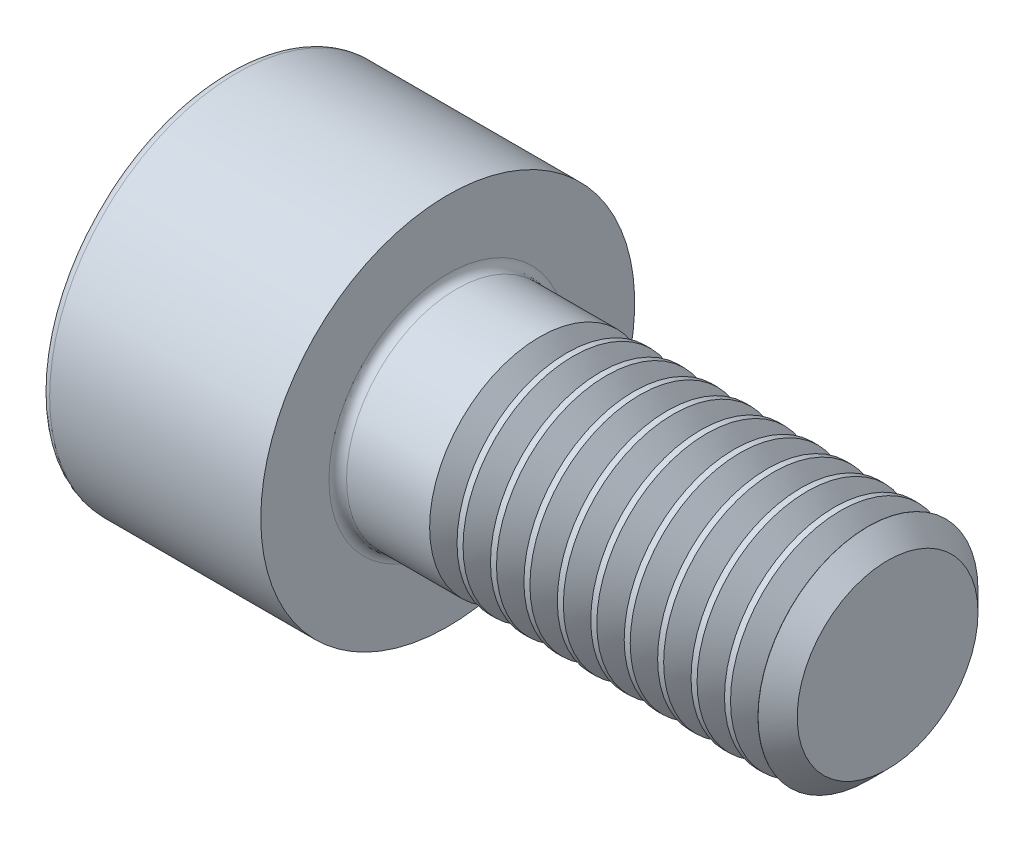
from build123d import *

# Parameters (mm, degrees)
SKETCH1_W            = 5
SKETCH1_H            = 4.25
SKETCH2_R            = 2.5
BOSS_EXTRUDE1_DEPTH  = 2.088407645
SKETCH3_R            = 2.5
BOSS_EXTRUDE2_DEPTH  = 0.311592355
BOSS_EXTRUDE2_TAPER  = 55
SKETCH4_R            = 2.055
BOSS_EXTRUDE3_DEPTH  = 0.311592355
BOSS_EXTRUDE3_TAPER  = -55
SKETCH5_R            = 2.5
BOSS_EXTRUDE4_DEPTH  = 0.136815291
SKETCH6_R            = 2.5
BOSS_EXTRUDE5_DEPTH  = 0.311592355
BOSS_EXTRUDE5_TAPER  = 55
SKETCH7_R            = 2.055
BOSS_EXTRUDE6_DEPTH  = 0.311592355
BOSS_EXTRUDE6_TAPER  = -55
SKETCH8_R            = 2.5
BOSS_EXTRUDE7_DEPTH  = 0.136815291
SKETCH9_R            = 2.5
BOSS_EXTRUDE8_DEPTH  = 0.311592355
BOSS_EXTRUDE8_TAPER  = 55
SKETCH10_R           = 2.055
BOSS_EXTRUDE9_DEPTH  = 0.311592355
BOSS_EXTRUDE9_TAPER  = -55
SKETCH11_R           = 2.5
BOSS_EXTRUDE10_DEPTH = 0.136815291
SKETCH12_R           = 2.5
BOSS_EXTRUDE11_DEPTH = 0.311592355
BOSS_EXTRUDE11_TAPER = 55
SKETCH13_R           = 2.055
BOSS_EXTRUDE12_DEPTH = 0.311592355
BOSS_EXTRUDE12_TAPER = -55
SKETCH14_R           = 2.5
BOSS_EXTRUDE13_DEPTH = 0.136815291
SKETCH15_R           = 2.5
BOSS_EXTRUDE14_DEPTH = 0.311592355
BOSS_EXTRUDE14_TAPER = 55
SKETCH16_R           = 2.055
BOSS_EXTRUDE15_DEPTH = 0.311592355
BOSS_EXTRUDE15_TAPER = -55
SKETCH17_R           = 2.5
BOSS_EXTRUDE16_DEPTH = 0.136815291
SKETCH18_R           = 2.5
BOSS_EXTRUDE17_DEPTH = 0.311592355
BOSS_EXTRUDE17_TAPER = 55
SKETCH19_R           = 2.055
BOSS_EXTRUDE18_DEPTH = 0.311592355
BOSS_EXTRUDE18_TAPER = -55
SKETCH20_R           = 2.5
BOSS_EXTRUDE19_DEPTH = 0.136815291
SKETCH21_R           = 2.5
BOSS_EXTRUDE20_DEPTH = 0.311592355
BOSS_EXTRUDE20_TAPER = 55
SKETCH22_R           = 2.055
BOSS_EXTRUDE21_DEPTH = 0.311592355
BOSS_EXTRUDE21_TAPER = -55
SKETCH23_R           = 2.5
BOSS_EXTRUDE22_DEPTH = 0.136815291
SKETCH24_R           = 2.5
BOSS_EXTRUDE23_DEPTH = 0.311592355
BOSS_EXTRUDE23_TAPER = 55
SKETCH25_R           = 2.055
BOSS_EXTRUDE24_DEPTH = 0.311592355
BOSS_EXTRUDE24_TAPER = -55
SKETCH26_R           = 2.5
BOSS_EXTRUDE25_DEPTH = 0.136815291
SKETCH27_R           = 2.5
BOSS_EXTRUDE26_DEPTH = 0.311592355
BOSS_EXTRUDE26_TAPER = 55
SKETCH28_R           = 2.055
BOSS_EXTRUDE27_DEPTH = 0.311592355
BOSS_EXTRUDE27_TAPER = -55
SKETCH29_R           = 2.5
BOSS_EXTRUDE28_DEPTH = 0.136815291
SKETCH30_R           = 2.5
BOSS_EXTRUDE29_DEPTH = 0.311592355
BOSS_EXTRUDE29_TAPER = 55
SKETCH31_R           = 2.055
BOSS_EXTRUDE30_DEPTH = 0.311592355
BOSS_EXTRUDE30_TAPER = -55
SKETCH32_R           = 2.5
BOSS_EXTRUDE31_DEPTH = 0.003407645
SKETCH33_R           = 2.5
BOSS_EXTRUDE32_DEPTH = 0.445
BOSS_EXTRUDE32_TAPER = 45
CUT_EXTRUDE1_DEPTH   = 2.5
FILLET1_R            = 0.2


with BuildPart() as part:
    # Sketch1 → Revolve1 (revolve)
    with BuildSketch(Plane(origin=(0, 0, 0), x_dir=(-1, 0, 0), z_dir=(0, 0, -1))):
        with Locations((6.290592114, 2.355818515)):
            Rectangle(SKETCH1_W, SKETCH1_H)
    revolve(axis=Axis((-3.790592114, 0.230818515, 0), (-1, 0, 0)))

    # Sketch2 → Boss-Extrude1 (add)
    with BuildSketch(Plane(origin=(-3.790592114, 0, 0), x_dir=(0, 0, -1), z_dir=(1, 0, 0))):
        with Locations((0, 0.230818515)):
            Circle(SKETCH2_R)
    extrude(amount=BOSS_EXTRUDE1_DEPTH)

    # Sketch3 → Boss-Extrude2 (add)
    with BuildSketch(Plane(origin=(-1.702184469, 0, 0), x_dir=(0, 0, -1), z_dir=(1, 0, 0))):
        with Locations((0, 0.230818515)):
            Circle(SKETCH3_R)
    extrude(amount=BOSS_EXTRUDE2_DEPTH, taper=BOSS_EXTRUDE2_TAPER)

    # Sketch4 → Boss-Extrude3 (add)
    with BuildSketch(Plane(origin=(-1.390592114, 0, 0), x_dir=(0, 0, -1), z_dir=(1, 0, 0))):
        with Locations((0, 0.230818515)):
            Circle(SKETCH4_R)
    extrude(amount=BOSS_EXTRUDE3_DEPTH, taper=BOSS_EXTRUDE3_TAPER)

    # Sketch5 → Boss-Extrude4 (add)
    with BuildSketch(Plane(origin=(-1.07899976, 0, 0), x_dir=(0, 0, -1), z_dir=(1, 0, 0))):
        with Locations((0, 0.230818515)):
            Circle(SKETCH5_R)
    extrude(amount=BOSS_EXTRUDE4_DEPTH)

    # Sketch6 → Boss-Extrude5 (add)
    with BuildSketch(Plane(origin=(-0.942184469, 0, 0), x_dir=(0, 0, -1), z_dir=(1, 0, 0))):
        with Locations((0, 0.230818515)):
            Circle(SKETCH6_R)
    extrude(amount=BOSS_EXTRUDE5_DEPTH, taper=BOSS_EXTRUDE5_TAPER)

    # Sketch7 → Boss-Extrude6 (add)
    with BuildSketch(Plane(origin=(-0.630592114, 0, 0), x_dir=(0, 0, -1), z_dir=(1, 0, 0))):
        with Locations((0, 0.230818515)):
            Circle(SKETCH7_R)
    extrude(amount=BOSS_EXTRUDE6_DEPTH, taper=BOSS_EXTRUDE6_TAPER)

    # Sketch8 → Boss-Extrude7 (add)
    with BuildSketch(Plane(origin=(-0.31899976, 0, 0), x_dir=(0, 0, -1), z_dir=(1, 0, 0))):
        with Locations((0, 0.230818515)):
            Circle(SKETCH8_R)
    extrude(amount=BOSS_EXTRUDE7_DEPTH)

    # Sketch9 → Boss-Extrude8 (add)
    with BuildSketch(Plane(origin=(-0.182184469, 0, 0), x_dir=(0, 0, -1), z_dir=(1, 0, 0))):
        with Locations((0, 0.230818515)):
            Circle(SKETCH9_R)
    extrude(amount=BOSS_EXTRUDE8_DEPTH, taper=BOSS_EXTRUDE8_TAPER)

    # Sketch10 → Boss-Extrude9 (add)
    with BuildSketch(Plane(origin=(0.129407886, 0, 0), x_dir=(0, 0, -1), z_dir=(1, 0, 0))):
        with Locations((0, 0.230818515)):
            Circle(SKETCH10_R)
    extrude(amount=BOSS_EXTRUDE9_DEPTH, taper=BOSS_EXTRUDE9_TAPER)

    # Sketch11 → Boss-Extrude10 (add)
    with BuildSketch(Plane(origin=(0.44100024, 0, 0), x_dir=(0, 0, -1), z_dir=(1, 0, 0))):
        with Locations((0, 0.230818515)):
            Circle(SKETCH11_R)
    extrude(amount=BOSS_EXTRUDE10_DEPTH)

    # Sketch12 → Boss-Extrude11 (add)
    with BuildSketch(Plane(origin=(0.577815531, 0, 0), x_dir=(0, 0, -1), z_dir=(1, 0, 0))):
        with Locations((0, 0.230818515)):
            Circle(SKETCH12_R)
    extrude(amount=BOSS_EXTRUDE11_DEPTH, taper=BOSS_EXTRUDE11_TAPER)

    # Sketch13 → Boss-Extrude12 (add)
    with BuildSketch(Plane(origin=(0.889407886, 0, 0), x_dir=(0, 0, -1), z_dir=(1, 0, 0))):
        with Locations((0, 0.230818515)):
            Circle(SKETCH13_R)
    extrude(amount=BOSS_EXTRUDE12_DEPTH, taper=BOSS_EXTRUDE12_TAPER)

    # Sketch14 → Boss-Extrude13 (add)
    with BuildSketch(Plane(origin=(1.20100024, 0, 0), x_dir=(0, 0, -1), z_dir=(1, 0, 0))):
        with Locations((0, 0.230818515)):
            Circle(SKETCH14_R)
    extrude(amount=BOSS_EXTRUDE13_DEPTH)

    # Sketch15 → Boss-Extrude14 (add)
    with BuildSketch(Plane(origin=(1.337815531, 0, 0), x_dir=(0, 0, -1), z_dir=(1, 0, 0))):
        with Locations((0, 0.230818515)):
            Circle(SKETCH15_R)
    extrude(amount=BOSS_EXTRUDE14_DEPTH, taper=BOSS_EXTRUDE14_TAPER)

    # Sketch16 → Boss-Extrude15 (add)
    with BuildSketch(Plane(origin=(1.649407886, 0, 0), x_dir=(0, 0, -1), z_dir=(1, 0, 0))):
        with Locations((0, 0.230818515)):
            Circle(SKETCH16_R)
    extrude(amount=BOSS_EXTRUDE15_DEPTH, taper=BOSS_EXTRUDE15_TAPER)

    # Sketch17 → Boss-Extrude16 (add)
    with BuildSketch(Plane(origin=(1.96100024, 0, 0), x_dir=(0, 0, -1), z_dir=(1, 0, 0))):
        with Locations((0, 0.230818515)):
            Circle(SKETCH17_R)
    extrude(amount=BOSS_EXTRUDE16_DEPTH)

    # Sketch18 → Boss-Extrude17 (add)
    with BuildSketch(Plane(origin=(2.097815531, 0, 0), x_dir=(0, 0, -1), z_dir=(1, 0, 0))):
        with Locations((0, 0.230818515)):
            Circle(SKETCH18_R)
    extrude(amount=BOSS_EXTRUDE17_DEPTH, taper=BOSS_EXTRUDE17_TAPER)

    # Sketch19 → Boss-Extrude18 (add)
    with BuildSketch(Plane(origin=(2.409407886, 0, 0), x_dir=(0, 0, -1), z_dir=(1, 0, 0))):
        with Locations((0, 0.230818515)):
            Circle(SKETCH19_R)
    extrude(amount=BOSS_EXTRUDE18_DEPTH, taper=BOSS_EXTRUDE18_TAPER)

    # Sketch20 → Boss-Extrude19 (add)
    with BuildSketch(Plane(origin=(2.72100024, 0, 0), x_dir=(0, 0, -1), z_dir=(1, 0, 0))):
        with Locations((0, 0.230818515)):
            Circle(SKETCH20_R)
    extrude(amount=BOSS_EXTRUDE19_DEPTH)

    # Sketch21 → Boss-Extrude20 (add)
    with BuildSketch(Plane(origin=(2.857815531, 0, 0), x_dir=(0, 0, -1), z_dir=(1, 0, 0))):
        with Locations((0, 0.230818515)):
            Circle(SKETCH21_R)
    extrude(amount=BOSS_EXTRUDE20_DEPTH, taper=BOSS_EXTRUDE20_TAPER)

    # Sketch22 → Boss-Extrude21 (add)
    with BuildSketch(Plane(origin=(3.169407886, 0, 0), x_dir=(0, 0, -1), z_dir=(1, 0, 0))):
        with Locations((0, 0.230818515)):
            Circle(SKETCH22_R)
    extrude(amount=BOSS_EXTRUDE21_DEPTH, taper=BOSS_EXTRUDE21_TAPER)

    # Sketch23 → Boss-Extrude22 (add)
    with BuildSketch(Plane(origin=(3.48100024, 0, 0), x_dir=(0, 0, -1), z_dir=(1, 0, 0))):
        with Locations((0, 0.230818515)):
            Circle(SKETCH23_R)
    extrude(amount=BOSS_EXTRUDE22_DEPTH)

    # Sketch24 → Boss-Extrude23 (add)
    with BuildSketch(Plane(origin=(3.617815531, 0, 0), x_dir=(0, 0, -1), z_dir=(1, 0, 0))):
        with Locations((0, 0.230818515)):
            Circle(SKETCH24_R)
    extrude(amount=BOSS_EXTRUDE23_DEPTH, taper=BOSS_EXTRUDE23_TAPER)

    # Sketch25 → Boss-Extrude24 (add)
    with BuildSketch(Plane(origin=(3.929407886, 0, 0), x_dir=(0, 0, -1), z_dir=(1, 0, 0))):
        with Locations((0, 0.230818515)):
            Circle(SKETCH25_R)
    extrude(amount=BOSS_EXTRUDE24_DEPTH, taper=BOSS_EXTRUDE24_TAPER)

    # Sketch26 → Boss-Extrude25 (add)
    with BuildSketch(Plane(origin=(4.24100024, 0, 0), x_dir=(0, 0, -1), z_dir=(1, 0, 0))):
        with Locations((0, 0.230818515)):
            Circle(SKETCH26_R)
    extrude(amount=BOSS_EXTRUDE25_DEPTH)

    # Sketch27 → Boss-Extrude26 (add)
    with BuildSketch(Plane(origin=(4.377815531, 0, 0), x_dir=(0, 0, -1), z_dir=(1, 0, 0))):
        with Locations((0, 0.230818515)):
            Circle(SKETCH27_R)
    extrude(amount=BOSS_EXTRUDE26_DEPTH, taper=BOSS_EXTRUDE26_TAPER)

    # Sketch28 → Boss-Extrude27 (add)
    with BuildSketch(Plane(origin=(4.689407886, 0, 0), x_dir=(0, 0, -1), z_dir=(1, 0, 0))):
        with Locations((0, 0.230818515)):
            Circle(SKETCH28_R)
    extrude(amount=BOSS_EXTRUDE27_DEPTH, taper=BOSS_EXTRUDE27_TAPER)

    # Sketch29 → Boss-Extrude28 (add)
    with BuildSketch(Plane(origin=(5.00100024, 0, 0), x_dir=(0, 0, -1), z_dir=(1, 0, 0))):
        with Locations((0, 0.230818515)):
            Circle(SKETCH29_R)
    extrude(amount=BOSS_EXTRUDE28_DEPTH)

    # Sketch30 → Boss-Extrude29 (add)
    with BuildSketch(Plane(origin=(5.137815531, 0, 0), x_dir=(0, 0, -1), z_dir=(1, 0, 0))):
        with Locations((0, 0.230818515)):
            Circle(SKETCH30_R)
    extrude(amount=BOSS_EXTRUDE29_DEPTH, taper=BOSS_EXTRUDE29_TAPER)

    # Sketch31 → Boss-Extrude30 (add)
    with BuildSketch(Plane(origin=(5.449407886, 0, 0), x_dir=(0, 0, -1), z_dir=(1, 0, 0))):
        with Locations((0, 0.230818515)):
            Circle(SKETCH31_R)
    extrude(amount=BOSS_EXTRUDE30_DEPTH, taper=BOSS_EXTRUDE30_TAPER)

    # Sketch32 → Boss-Extrude31 (add)
    with BuildSketch(Plane(origin=(5.76100024, 0, 0), x_dir=(0, 0, -1), z_dir=(1, 0, 0))):
        with Locations((0, 0.230818515)):
            Circle(SKETCH32_R)
    extrude(amount=BOSS_EXTRUDE31_DEPTH)

    # Sketch33 → Boss-Extrude32 (add)
    with BuildSketch(Plane(origin=(5.764407886, 0, 0), x_dir=(0, 0, -1), z_dir=(1, 0, 0))):
        with Locations((0, 0.230818515)):
            Circle(SKETCH33_R)
    extrude(amount=BOSS_EXTRUDE32_DEPTH, taper=BOSS_EXTRUDE32_TAPER)

    # Sketch34 → Cut-Extrude1 (cut)
    with BuildSketch(Plane.ZY.offset(8.790592114)):
        Polygon((0, -2.127079985), (2.042, -0.948130735), (2.042, 1.409767764), (0, 2.588717014), (-2.042, 1.409767764), (-2.042, -0.948130735), align=None)
    extrude(amount=-CUT_EXTRUDE1_DEPTH, mode=Mode.SUBTRACT)

    # Sketch35 → Cut-Revolve1 (revolve, cut)
    with BuildSketch(Plane.XY):
        Polygon((-6.290592114, 2.272818515), (-6.290592114, 0.230818515), (-5.111642864, 0.230818515), align=None)
    revolve(axis=Axis((-6.290592114, 0.230818515, 0), (1, 0, 0)), mode=Mode.SUBTRACT)

    # Fillet1
    fillet1_edges = [part.edges().sort_by_distance(p)[0] for p in [
        (-8.790592114, -4.019181485, 0),
        (-3.790592114, 0.230818515, 2.5),
    ]]
    fillet(fillet1_edges, radius=FILLET1_R)


solid = part.part
